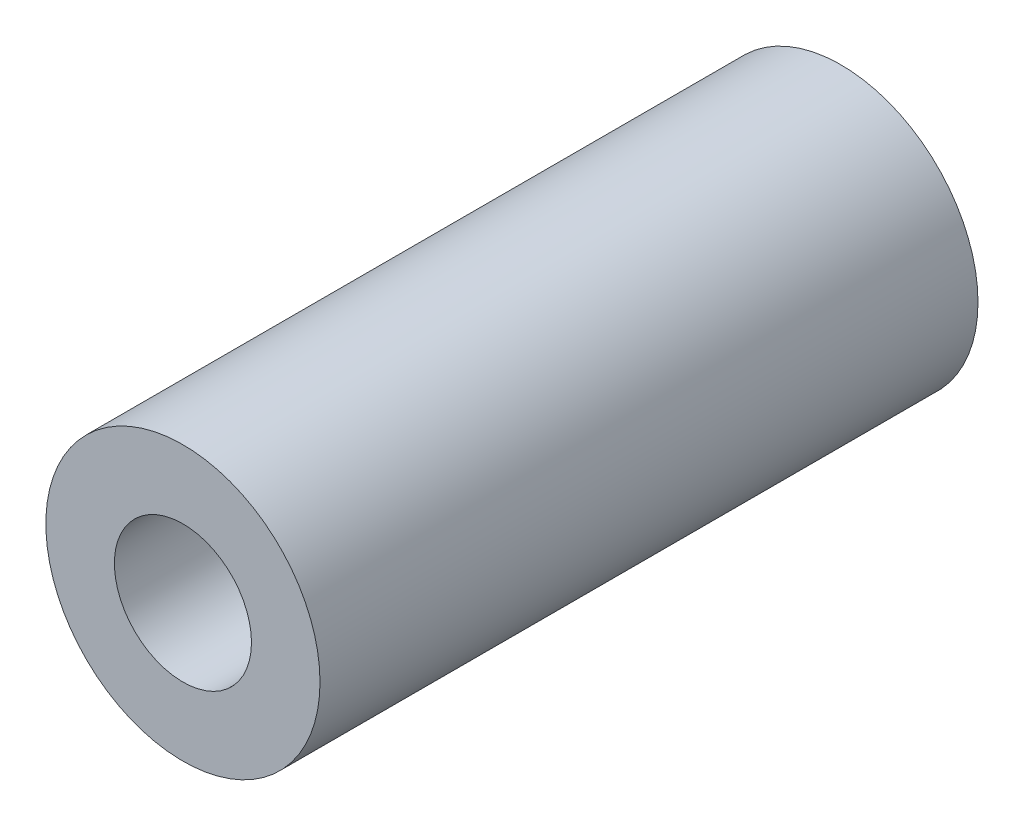
from build123d import *

# Parameters (mm, degrees)
SKETCH_1_R         = 2.5
EXTRUDE_1_DEPTH    = 12
HOLE_WIZARD_M3_1_D = 2.5


with BuildPart() as part:
    # 草图1 → 凸台-拉伸1 (new body)
    with BuildSketch(Plane.XY):
        Circle(SKETCH_1_R)
    extrude(amount=EXTRUDE_1_DEPTH)

    # M3 螺纹孔1 (through all)
    with Locations(Plane.XY.offset(12)):
        with Locations((0, 0)):
            Hole(HOLE_WIZARD_M3_1_D / 2)


solid = part.part
